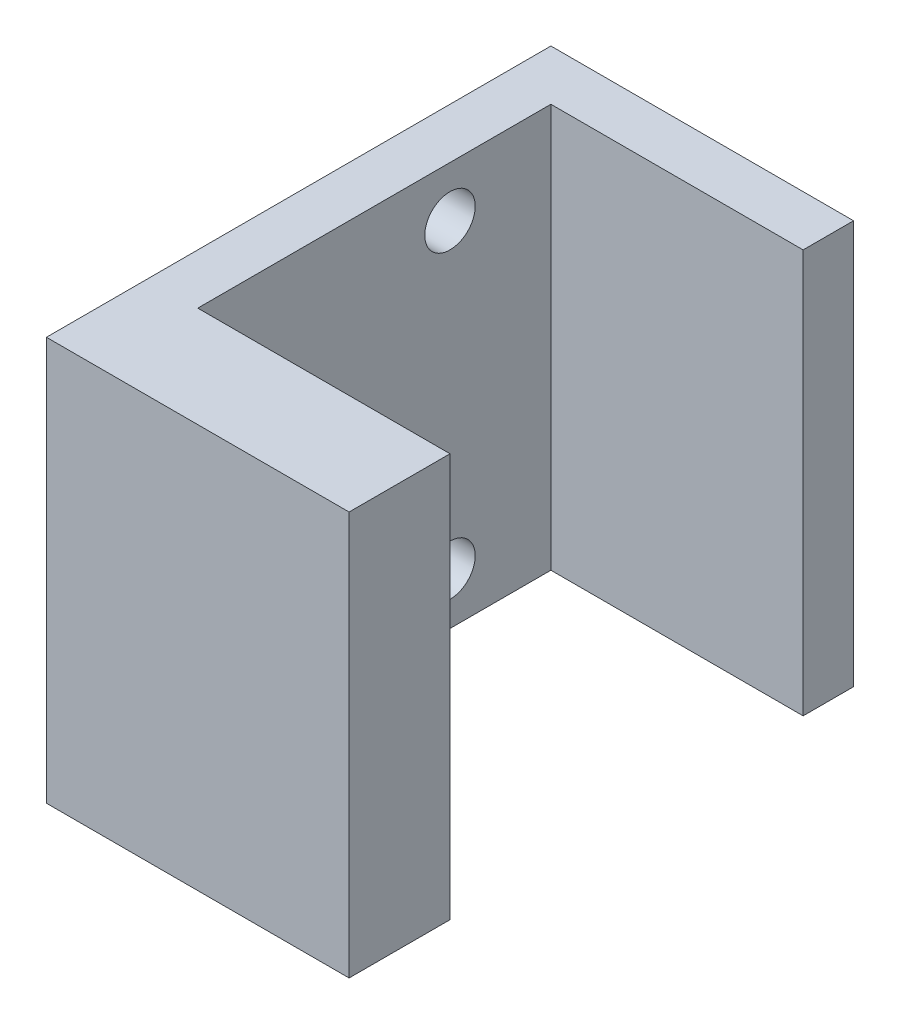
from build123d import *

# Parameters (mm, degrees)
BOSS_EXTRUDE1_DEPTH = 200
HOLE1_D             = 25


with BuildPart() as part:
    # Sketch1 → Boss-Extrude1 (new body)
    with BuildSketch(Plane(origin=(0, 0, 0), x_dir=(1, 0, 0), z_dir=(0, 1, 0))):
        Polygon((0, 225), (0, 250), (-150, 250), (-150, 0), (0, 0), (0, 50), (-125, 50), (-125, 225), align=None)
    extrude(amount=BOSS_EXTRUDE1_DEPTH)

    # Hole1 (through all)
    with Locations(Plane(origin=(-150, 175, -175), x_dir=(0, 0, -1), z_dir=(-1, 0, 0))):
        with Locations((0, 0), (0, 150)):
            Hole(HOLE1_D / 2)


solid = part.part
